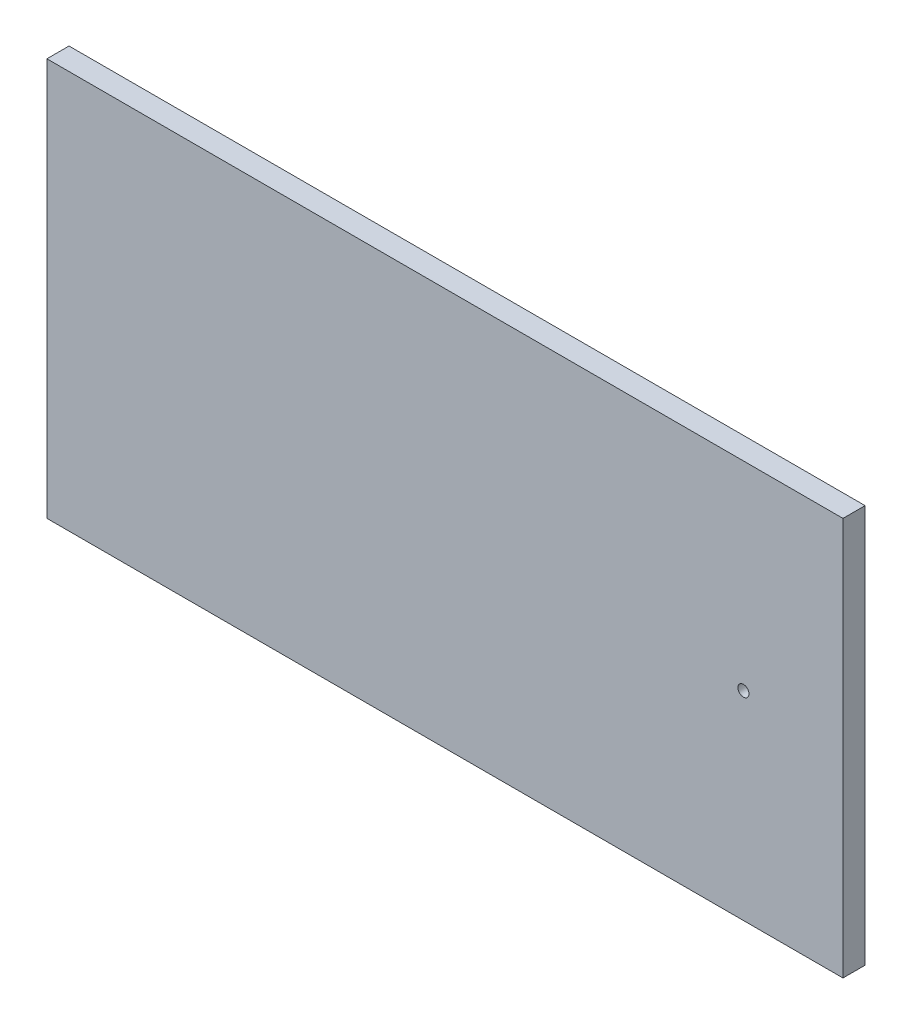
from build123d import *

# Parameters (mm, degrees)
SKETCH2_W           = 457.2
SKETCH2_H           = 228.6
BOSS_EXTRUDE1_DEPTH = 12.7
SKETCH3_R           = 3.175
CUT_EXTRUDE1_DEPTH  = 12.7


with BuildPart() as part:
    # Sketch2 → Boss-Extrude1 (new body)
    with BuildSketch(Plane.XY):
        with Locations((228.6, -114.3)):
            Rectangle(SKETCH2_W, SKETCH2_H)
    extrude(amount=BOSS_EXTRUDE1_DEPTH)

    # Sketch3 → Cut-Extrude1 (cut)
    with BuildSketch(Plane.XY.offset(12.7)):
        with Locations((400.05, -114.3)):
            Circle(SKETCH3_R)
    extrude(amount=-CUT_EXTRUDE1_DEPTH, mode=Mode.SUBTRACT)


solid = part.part
